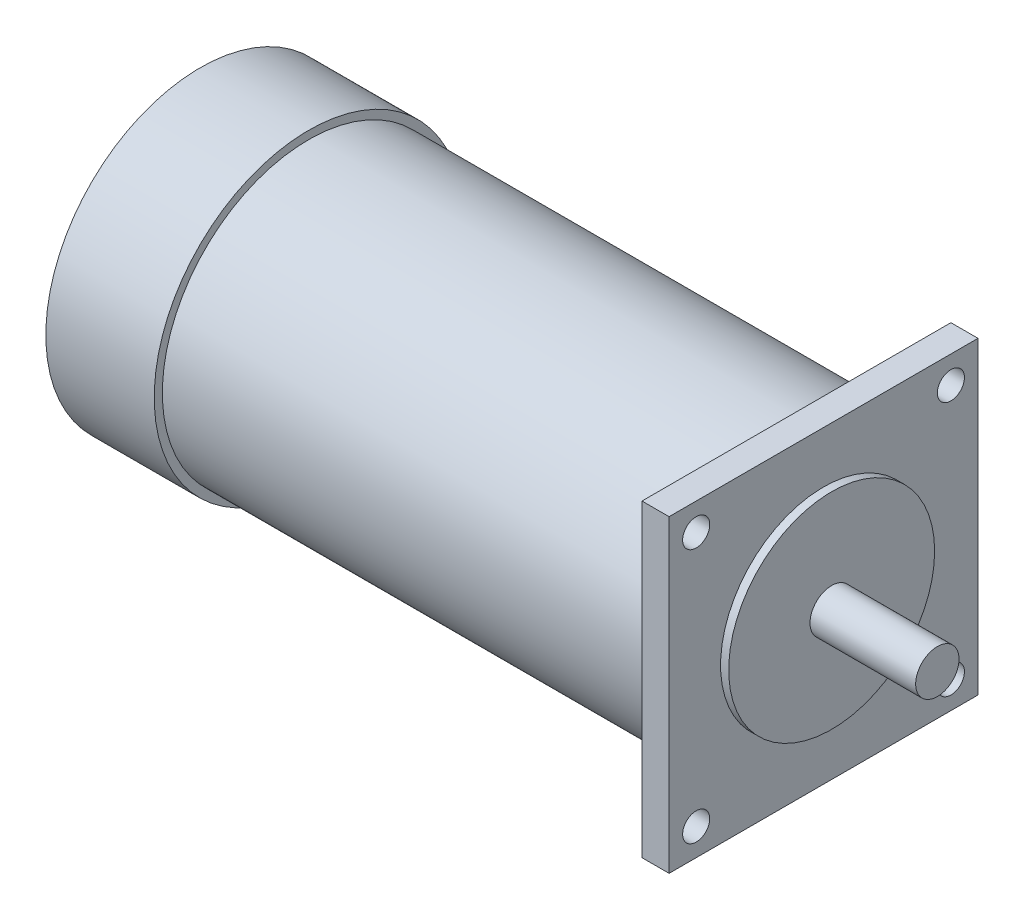
from build123d import *

# Parameters (mm, degrees)
SKETCH_1_R          = 4
EXTRUDE_1_DEPTH     = 21
SKETCH_1_3_R        = 19
SKETCH_1_3_R_2      = 4
EXTRUDE_2_DEPTH     = 1.5
SKETCH_1_4_W        = 57
SKETCH_1_4_H        = 57
SKETCH_1_4_R        = 19
EXTRUDE_3_DEPTH     = 115
SKETCH_9_OUTSIDE_W  = 90.618
SKETCH_9_OUTSIDE_H  = 90.618
SKETCH_9_OUTSIDE_R  = 28.5
CUT_EXTRUDE_1_DEPTH = 20
SKETCH_11_OUTSIDE_W = 90.618
SKETCH_11_OUTSIDE_H = 90.618
SKETCH_11_OUTSIDE_R = 27
CUT_EXTRUDE_2_DEPTH = 90
SKETCH_16_R         = 2.5
CUT_EXTRUDE_3_DEPTH = 5


with BuildPart() as part:
    # 草图1 → 凸台-拉伸1 (new body)
    with BuildSketch(Plane(origin=(0, 0, 0), x_dir=(0, 0, -1), z_dir=(1, 0, 0))):
        Circle(SKETCH_1_R)
    extrude(amount=EXTRUDE_1_DEPTH)

    # 草图1<3> → 凸台-拉伸2 (add)
    with BuildSketch(Plane(origin=(0, 0, 0), x_dir=(0, 0, -1), z_dir=(1, 0, 0))):
        Circle(SKETCH_1_3_R)
        Circle(SKETCH_1_3_R_2, mode=Mode.SUBTRACT)
    extrude(amount=EXTRUDE_2_DEPTH)


with BuildPart() as body_2:
    # 草图1<4> → 凸台-拉伸3 (new body)
    with BuildSketch(Plane(origin=(0, 0, 0), x_dir=(0, 0, -1), z_dir=(1, 0, 0))):
        Rectangle(SKETCH_1_4_W, SKETCH_1_4_H)
        Circle(SKETCH_1_4_R, mode=Mode.SUBTRACT)
    extrude(amount=-EXTRUDE_3_DEPTH)

    # 草图9 outside → 切除-拉伸1 (cut)
    with BuildSketch(Plane(origin=(-115, 0, 0), x_dir=(0, 0, -1), z_dir=(1, 0, 0))):
        Rectangle(SKETCH_9_OUTSIDE_W, SKETCH_9_OUTSIDE_H)
        Circle(SKETCH_9_OUTSIDE_R, mode=Mode.SUBTRACT)
    extrude(amount=CUT_EXTRUDE_1_DEPTH, mode=Mode.SUBTRACT)

    # 草图11 outside → 切除-拉伸2 (cut)
    with BuildSketch(Plane(origin=(-95, 0, 0), x_dir=(0, 0, -1), z_dir=(1, 0, 0))):
        Rectangle(SKETCH_11_OUTSIDE_W, SKETCH_11_OUTSIDE_H)
        Circle(SKETCH_11_OUTSIDE_R, mode=Mode.SUBTRACT)
    extrude(amount=CUT_EXTRUDE_2_DEPTH, mode=Mode.SUBTRACT)

    # 草图16 → 切除-拉伸3 (cut)
    with BuildSketch(Plane(origin=(0, 0, 0), x_dir=(0, 0, -1), z_dir=(1, 0, 0))):
        with Locations((-23.5, 23.5)):
            Circle(SKETCH_16_R)
        with Locations((23.5, 23.5)):
            Circle(SKETCH_16_R)
        with Locations((23.5, -23.5)):
            Circle(SKETCH_16_R)
        with Locations((-23.5, -23.5)):
            Circle(SKETCH_16_R)
    extrude(amount=-CUT_EXTRUDE_3_DEPTH, mode=Mode.SUBTRACT)


solid = Compound([part.part, body_2.part])
